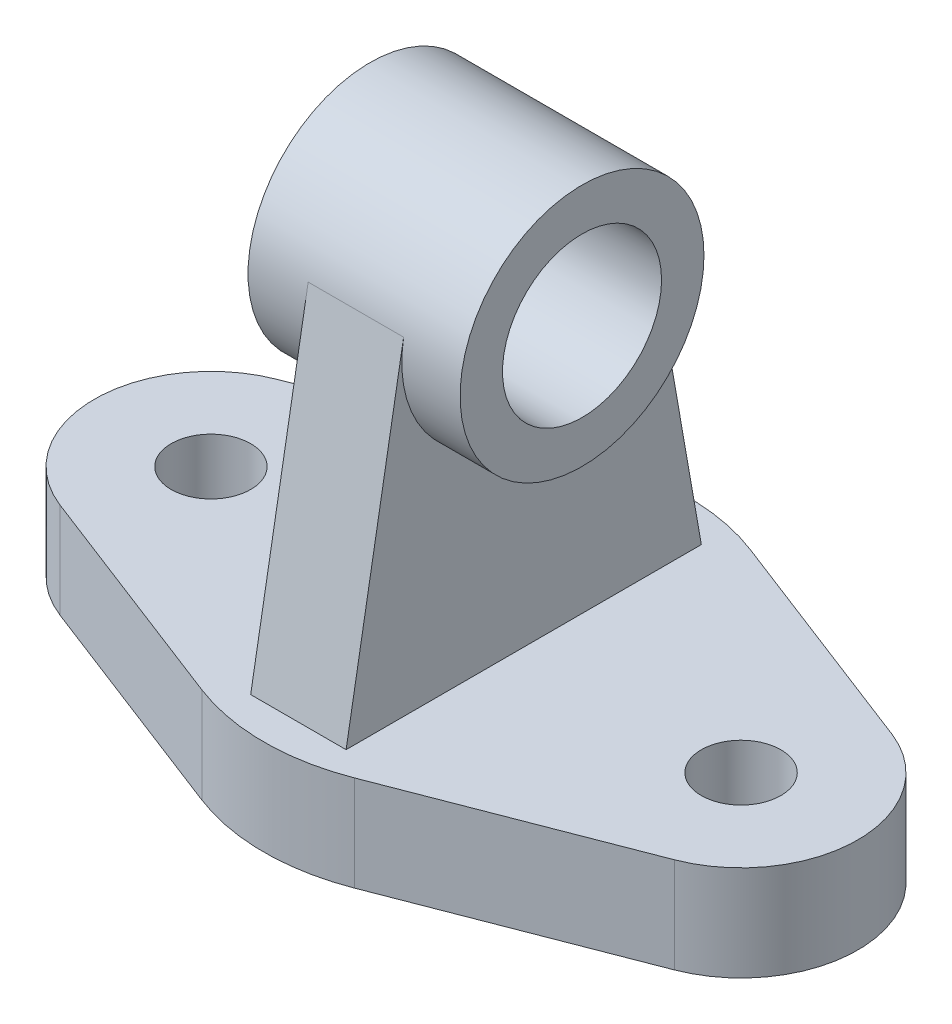
from build123d import *

# Parameters (mm, degrees)
SKETCH_1_R      = 7.5
EXTRUDE_1_DEPTH = 18
SKETCH_2_R      = 15
EXTRUDE_2_DEPTH = 20
EXTRUDE_3_DEPTH = 9


with BuildPart() as part:
    # 草圖1 → 填料-伸長1 (new body)
    with BuildSketch(Plane(origin=(0, 0, 0), x_dir=(1, 0, 0), z_dir=(0, 1, 0))):
        with BuildLine():
            Line((-57.92, -20.52495067), (-14.4, -37.318092127))
            ThreePointArc((-14.4, -37.318092127), (0, -40), (14.4, -37.318092127))
            Line((14.4, -37.318092127), (57.92, -20.52495067))
            ThreePointArc((57.92, -20.52495067), (72, 0), (57.92, 20.52495067))
            Line((57.92, 20.52495067), (14.4, 37.318092127))
            ThreePointArc((14.4, 37.318092127), (0, 40), (-14.4, 37.318092127))
            Line((-14.4, 37.318092127), (-57.92, 20.52495067))
            ThreePointArc((-57.92, 20.52495067), (-72, 0), (-57.92, -20.52495067))
        make_face()
        with Locations((50, 0)):
            Circle(SKETCH_1_R, mode=Mode.SUBTRACT)
        with Locations((-50, 0)):
            Circle(SKETCH_1_R, mode=Mode.SUBTRACT)
    extrude(amount=EXTRUDE_1_DEPTH)



with BuildPart() as body_2:
    # 草圖2 → 填料-伸長2 (new, symmetric)
    with BuildSketch(Plane(origin=(0, 0, 0), x_dir=(0, 0, -1), z_dir=(1, 0, 0))):
        with BuildLine():
            ThreePointArc((22.655671663, 79.964913806), (0, 99), (-22.655671663, 79.964913806))
            ThreePointArc((-22.655671663, 79.964913806), (-1.989918559, 53.08624378), (23, 76))
            ThreePointArc((23, 76), (22.91375622, 77.989918559), (22.655671663, 79.964913806))
        make_face()
        with Locations((0, 76)):
            Circle(SKETCH_2_R, mode=Mode.SUBTRACT)
    extrude(amount=EXTRUDE_2_DEPTH, both=True)


with BuildPart() as part_1:
    add(part.part)

    add(body_2.part)  # 填料-伸長3 merges body 2
    # 草圖2<3> → 填料-伸長3 (add, symmetric)
    with BuildSketch(Plane(origin=(0, 0, 0), x_dir=(0, 0, -1), z_dir=(1, 0, 0))):
        with BuildLine():
            ThreePointArc((23, 76), (-1.989918559, 53.08624378), (-22.655671663, 79.964913806))
            Line((-22.655671663, 79.964913806), (-33.5, 18))
            Line((-33.5, 18), (33.5, 18))
            Line((33.5, 18), (22.655671663, 79.964913806))
            ThreePointArc((22.655671663, 79.964913806), (22.91375622, 77.989918559), (23, 76))
        make_face()
    extrude(amount=EXTRUDE_3_DEPTH, both=True)


solid = part_1.part
